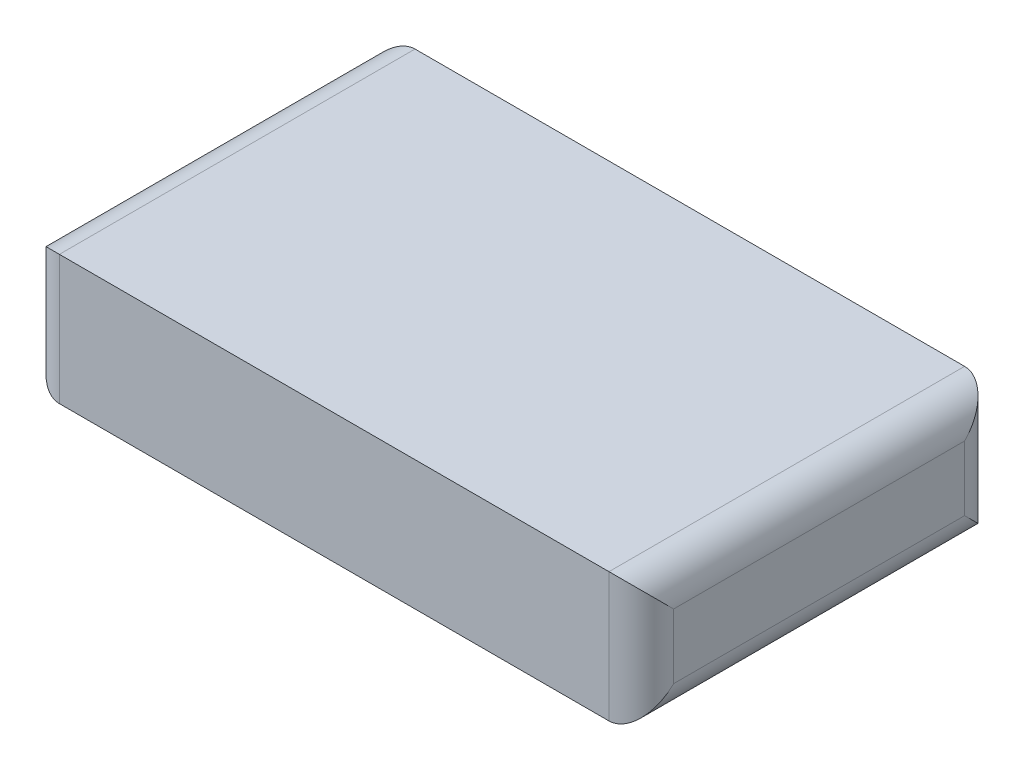
from build123d import *

# Parameters (mm, degrees)
SKETCH_1_W      = 19
SKETCH_1_H      = 11
EXTRUDE_1_DEPTH = 4
FILLET_1_R      = 1


with BuildPart() as part:
    # 草图1 → 凸台-拉伸1 (new body)
    with BuildSketch(Plane(origin=(0, 0, 0), x_dir=(1, 0, 0), z_dir=(0, 1, 0))):
        with Locations((-8.5, 1.203125)):
            Rectangle(SKETCH_1_W, SKETCH_1_H)
    extrude(amount=EXTRUDE_1_DEPTH)

    # 圆角1
    fillet_1_edges = [part.edges().sort_by_distance(p)[0] for p in [
        (-18, 4, -1.203125),
        (1, 4, -1.203125),
        (-18, 0, -1.203125),
        (1, 0, -1.203125),
        (1, 2, 4.296875),
        (-18, 2, 4.296875),
        (-18, 2, -6.703125),
        (1, 2, -6.703125),
    ]]
    fillet(fillet_1_edges, radius=FILLET_1_R)


solid = part.part
